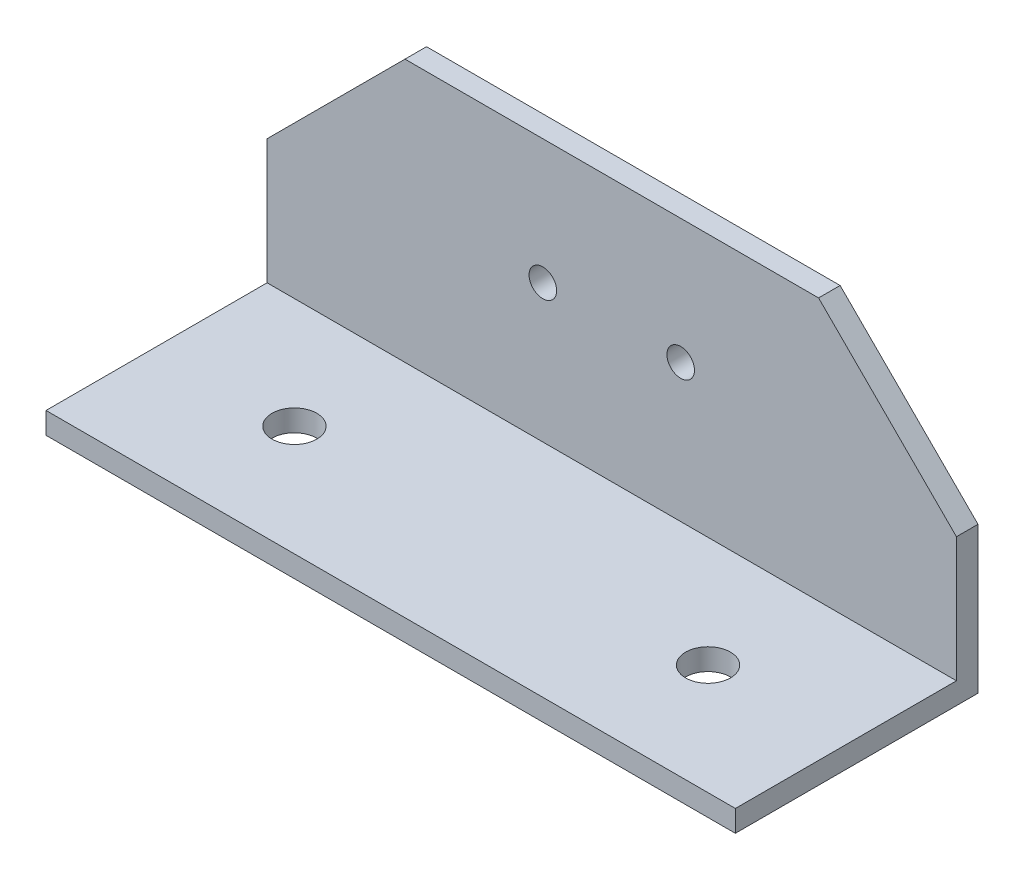
from build123d import *

# Parameters (mm, degrees)
EXTRUDE_THIN1_DEPTH = 100
SKETCH2_R           = 2
CUT_EXTRUDE1_DEPTH  = 36.197996578
CHAMFER1_SIZE       = 20
SKETCH3_R           = 3.25
CUT_EXTRUDE2_DEPTH  = 4.125


with BuildPart() as part:
    # Sketch1 → Extrude-Thin1 (new body)
    with BuildSketch(Plane(origin=(0, 0, 0), x_dir=(0, 0, -1), z_dir=(1, 0, 0))):
        Polygon((0, 0), (32.072996578, 0), (32.072996578, 38.1), (35.197996578, 38.1), (35.197996578, -3.125), (0, -3.125), align=None)
    extrude(amount=EXTRUDE_THIN1_DEPTH)

    # Sketch2 → Cut-Extrude1 (cut, through all)
    with BuildSketch(Plane(origin=(0, 0, -35.197996578), x_dir=(-1, 0, 0), z_dir=(0, 0, -1))):
        with Locations(Location((-40, 20, 0), (0, 0, 180))):  # turned: the seam where the file's is
            Circle(SKETCH2_R)
        with Locations((-60, 20)):
            Circle(SKETCH2_R)
    extrude(amount=-CUT_EXTRUDE1_DEPTH, mode=Mode.SUBTRACT)

    # Chamfer1
    chamfer1_edges = [part.edges().sort_by_distance(p)[0] for p in [
        (0, 38.1, -33.635496578),
        (100, 38.1, -33.635496578),
    ]]
    chamfer(chamfer1_edges, length=CHAMFER1_SIZE)

    # Sketch3 → Cut-Extrude2 (cut, through all)
    with BuildSketch(Plane(origin=(0, 0, 0), x_dir=(-1, 0, 0), z_dir=(0, 1, 0))):
        with Locations(Location((-80, -16.036498289, 0), (0, 0, 90))):  # turned: the seam where the file's is
            Circle(SKETCH3_R)
        with Locations(Location((-20, -16.036498289, 0), (0, 0, 270))):  # turned: the seam where the file's is
            Circle(SKETCH3_R)
    extrude(amount=-CUT_EXTRUDE2_DEPTH, mode=Mode.SUBTRACT)


solid = part.part
